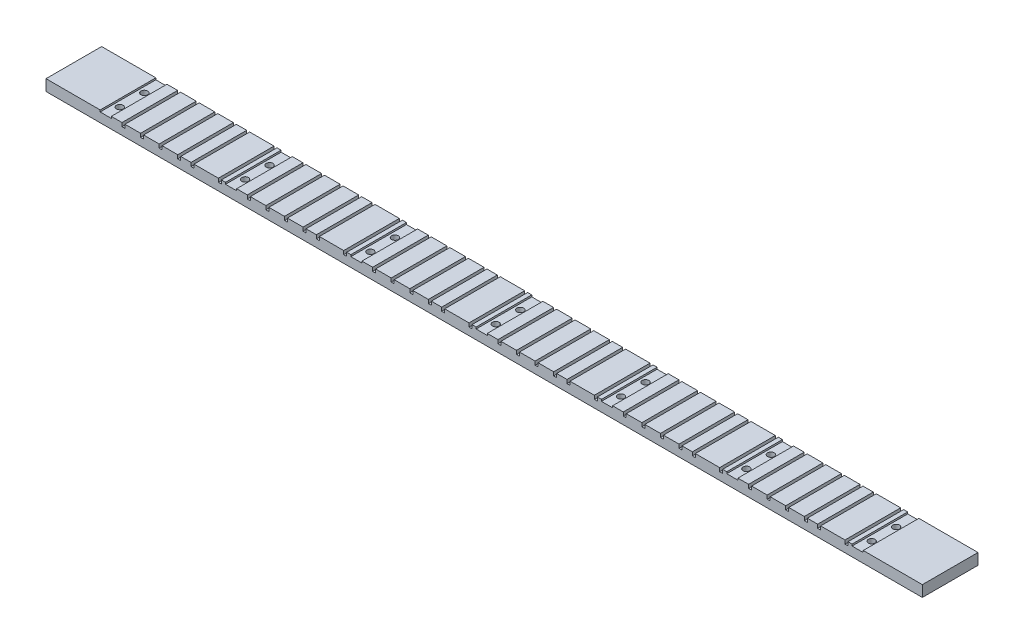
from build123d import *

# Parameters (mm, degrees)
SKETCH1_W           = 500
SKETCH1_H           = 31.75
BOSS_EXTRUDE1_DEPTH = 6.35
CUT_EXTRUDE2_DEPTH  = 32.75
CUT_EXTRUDE4_DEPTH  = 32.75
SKETCH6_R           = 1.89865
CUT_EXTRUDE3_DEPTH  = 6.35


with BuildPart() as part:
    # Sketch1 → Boss-Extrude1 (new body)
    with BuildSketch(Plane(origin=(0, 2, 0), x_dir=(-1, 0, 0), z_dir=(0, -1, 0))):
        with Locations((-150, 35.875)):
            Rectangle(SKETCH1_W, SKETCH1_H)
    extrude(amount=BOSS_EXTRUDE1_DEPTH)

    # Sketch5 → Cut-Extrude2 (cut, through all)
    with BuildSketch(Plane(origin=(0, 0, -51.75), x_dir=(-1, 0, 0), z_dir=(0, 0, -1))):
        Polygon((-1.574705718, 2.00006084), (-0.057166038, 2.00006084), (-0.057166038, -0.05708916), (1.644633962, -0.05708916), (1.644633962, 2.00006084), (15.542833962, 2.00006084), (15.542833962, -0.05708916), (17.244633962, -0.05708916), (17.244633962, 2.00006084), (23.142833962, 2.00006084), (23.142833962, -0.05708916), (24.844633962, -0.05708916), (24.844633962, 2.00006084), (33.742833962, 2.00006084), (33.742833962, -0.05708916), (35.444633962, -0.05708916), (35.444633962, 2.00006084), (44.342833962, 2.00006084), (44.342833962, -0.05708916), (46.044633962, -0.05708916), (46.044633962, 2.00006084), (54.942833962, 2.00006084), (54.942833962, -0.05708916), (56.644633962, -0.05708916), (56.644633962, 2.00006084), (61.710485811, 2.00006084), (61.710485811, 3.366834616), (-1.574705718, 3.366834616), align=None)
        Polygon((-73.074705718, 2.00006084), (-71.557166038, 2.00006084), (-71.557166038, -0.05708916), (-69.855366038, -0.05708916), (-69.855366038, 2.00006084), (-55.957166038, 2.00006084), (-55.957166038, -0.05708916), (-54.255366038, -0.05708916), (-54.255366038, 2.00006084), (-48.357166038, 2.00006084), (-48.357166038, -0.05708916), (-46.655366038, -0.05708916), (-46.655366038, 2.00006084), (-37.757166038, 2.00006084), (-37.757166038, -0.05708916), (-36.055366038, -0.05708916), (-36.055366038, 2.00006084), (-27.157166038, 2.00006084), (-27.157166038, -0.05708916), (-25.455366038, -0.05708916), (-25.455366038, 2.00006084), (-16.557166038, 2.00006084), (-16.557166038, -0.05708916), (-14.855366038, -0.05708916), (-14.855366038, 2.00006084), (-9.789514189, 2.00006084), (-9.789514189, 3.366834616), (-73.074705718, 3.366834616), align=None)
        Polygon((-144.574705718, 2.00006084), (-143.057166038, 2.00006084), (-143.057166038, -0.05708916), (-141.355366038, -0.05708916), (-141.355366038, 2.00006084), (-127.457166038, 2.00006084), (-127.457166038, -0.05708916), (-125.755366038, -0.05708916), (-125.755366038, 2.00006084), (-119.857166038, 2.00006084), (-119.857166038, -0.05708916), (-118.155366038, -0.05708916), (-118.155366038, 2.00006084), (-109.257166038, 2.00006084), (-109.257166038, -0.05708916), (-107.555366038, -0.05708916), (-107.555366038, 2.00006084), (-98.657166038, 2.00006084), (-98.657166038, -0.05708916), (-96.955366038, -0.05708916), (-96.955366038, 2.00006084), (-88.057166038, 2.00006084), (-88.057166038, -0.05708916), (-86.355366038, -0.05708916), (-86.355366038, 2.00006084), (-81.289514189, 2.00006084), (-81.289514189, 3.366834616), (-144.574705718, 3.366834616), align=None)
        Polygon((-216.074705718, 2.00006084), (-214.557166038, 2.00006084), (-214.557166038, -0.05708916), (-212.855366038, -0.05708916), (-212.855366038, 2.00006084), (-198.957166038, 2.00006084), (-198.957166038, -0.05708916), (-197.255366038, -0.05708916), (-197.255366038, 2.00006084), (-191.357166038, 2.00006084), (-191.357166038, -0.05708916), (-189.655366038, -0.05708916), (-189.655366038, 2.00006084), (-180.757166038, 2.00006084), (-180.757166038, -0.05708916), (-179.055366038, -0.05708916), (-179.055366038, 2.00006084), (-170.157166038, 2.00006084), (-170.157166038, -0.05708916), (-168.455366038, -0.05708916), (-168.455366038, 2.00006084), (-159.557166038, 2.00006084), (-159.557166038, -0.05708916), (-157.855366038, -0.05708916), (-157.855366038, 2.00006084), (-152.789514189, 2.00006084), (-152.789514189, 3.366834616), (-216.074705718, 3.366834616), align=None)
        Polygon((-287.574705718, 2.00006084), (-286.057166038, 2.00006084), (-286.057166038, -0.05708916), (-284.355366038, -0.05708916), (-284.355366038, 2.00006084), (-270.457166038, 2.00006084), (-270.457166038, -0.05708916), (-268.755366038, -0.05708916), (-268.755366038, 2.00006084), (-262.857166038, 2.00006084), (-262.857166038, -0.05708916), (-261.155366038, -0.05708916), (-261.155366038, 2.00006084), (-252.257166038, 2.00006084), (-252.257166038, -0.05708916), (-250.555366038, -0.05708916), (-250.555366038, 2.00006084), (-241.657166038, 2.00006084), (-241.657166038, -0.05708916), (-239.955366038, -0.05708916), (-239.955366038, 2.00006084), (-231.057166038, 2.00006084), (-231.057166038, -0.05708916), (-229.355366038, -0.05708916), (-229.355366038, 2.00006084), (-224.289514189, 2.00006084), (-224.289514189, 3.366834616), (-287.574705718, 3.366834616), align=None)
        Polygon((-359.074705718, 2.00006084), (-357.557166038, 2.00006084), (-357.557166038, -0.05708916), (-355.855366038, -0.05708916), (-355.855366038, 2.00006084), (-341.957166038, 2.00006084), (-341.957166038, -0.05708916), (-340.255366038, -0.05708916), (-340.255366038, 2.00006084), (-334.357166038, 2.00006084), (-334.357166038, -0.05708916), (-332.655366038, -0.05708916), (-332.655366038, 2.00006084), (-323.757166038, 2.00006084), (-323.757166038, -0.05708916), (-322.055366038, -0.05708916), (-322.055366038, 2.00006084), (-313.157166038, 2.00006084), (-313.157166038, -0.05708916), (-311.455366038, -0.05708916), (-311.455366038, 2.00006084), (-302.557166038, 2.00006084), (-302.557166038, -0.05708916), (-300.855366038, -0.05708916), (-300.855366038, 2.00006084), (-295.789514189, 2.00006084), (-295.789514189, 3.366834616), (-359.074705718, 3.366834616), align=None)
    extrude(amount=-CUT_EXTRUDE2_DEPTH, mode=Mode.SUBTRACT)

    # Sketch7 → Cut-Extrude4 (cut, through all)
    with BuildSketch(Plane.XY.offset(-20)):
        Polygon((-71.119952612, 3.645294213), (-71.119952612, 2), (-69.091918949, 2), (-69.091918949, 1), (-62.741918949, 1), (-62.741918949, 2), (-60.964008322, 2), (-60.964008322, 3.645294213), align=None)
        Polygon((0.380047388, 3.645294213), (0.380047388, 2), (2.408081051, 2), (2.408081051, 1), (8.758081051, 1), (8.758081051, 2), (10.535991678, 2), (10.535991678, 3.645294213), align=None)
        Polygon((71.880047388, 3.645294213), (71.880047388, 2), (73.908081051, 2), (73.908081051, 1), (80.258081051, 1), (80.258081051, 2), (82.035991678, 2), (82.035991678, 3.645294213), align=None)
        Polygon((143.380047388, 3.645294213), (143.380047388, 2), (145.408081051, 2), (145.408081051, 1), (151.758081051, 1), (151.758081051, 2), (153.535991678, 2), (153.535991678, 3.645294213), align=None)
        Polygon((214.880047388, 3.645294213), (214.880047388, 2), (216.908081051, 2), (216.908081051, 1), (223.258081051, 1), (223.258081051, 2), (225.035991678, 2), (225.035991678, 3.645294213), align=None)
        Polygon((286.380047388, 3.645294213), (286.380047388, 2), (288.408081051, 2), (288.408081051, 1), (294.758081051, 1), (294.758081051, 2), (296.535991678, 2), (296.535991678, 3.645294213), align=None)
        Polygon((357.880047388, 3.645294213), (357.880047388, 2), (359.908081051, 2), (359.908081051, 1), (366.258081051, 1), (366.258081051, 2), (368.035991678, 2), (368.035991678, 3.645294213), align=None)
    extrude(amount=-CUT_EXTRUDE4_DEPTH, mode=Mode.SUBTRACT)

    # Sketch6 → Cut-Extrude3 (cut, through all)
    with BuildSketch(Plane.XZ.offset(-1)):
        with Locations((-65.916918949, -42)):
            Circle(SKETCH6_R)
        with Locations((-65.916918949, -28)):
            Circle(SKETCH6_R)
        with Locations((5.583081051, -42)):
            Circle(SKETCH6_R)
        with Locations((5.583081051, -28)):
            Circle(SKETCH6_R)
        with Locations((77.083081051, -42)):
            Circle(SKETCH6_R)
        with Locations((77.083081051, -28)):
            Circle(SKETCH6_R)
        with Locations((148.583081051, -42)):
            Circle(SKETCH6_R)
        with Locations((148.583081051, -28)):
            Circle(SKETCH6_R)
        with Locations((220.083081051, -42)):
            Circle(SKETCH6_R)
        with Locations((220.083081051, -28)):
            Circle(SKETCH6_R)
        with Locations((291.583081051, -42)):
            Circle(SKETCH6_R)
        with Locations((291.583081051, -28)):
            Circle(SKETCH6_R)
        with Locations((363.083081051, -42)):
            Circle(SKETCH6_R)
        with Locations((363.083081051, -28)):
            Circle(SKETCH6_R)
    extrude(amount=CUT_EXTRUDE3_DEPTH, mode=Mode.SUBTRACT)


solid = part.part
